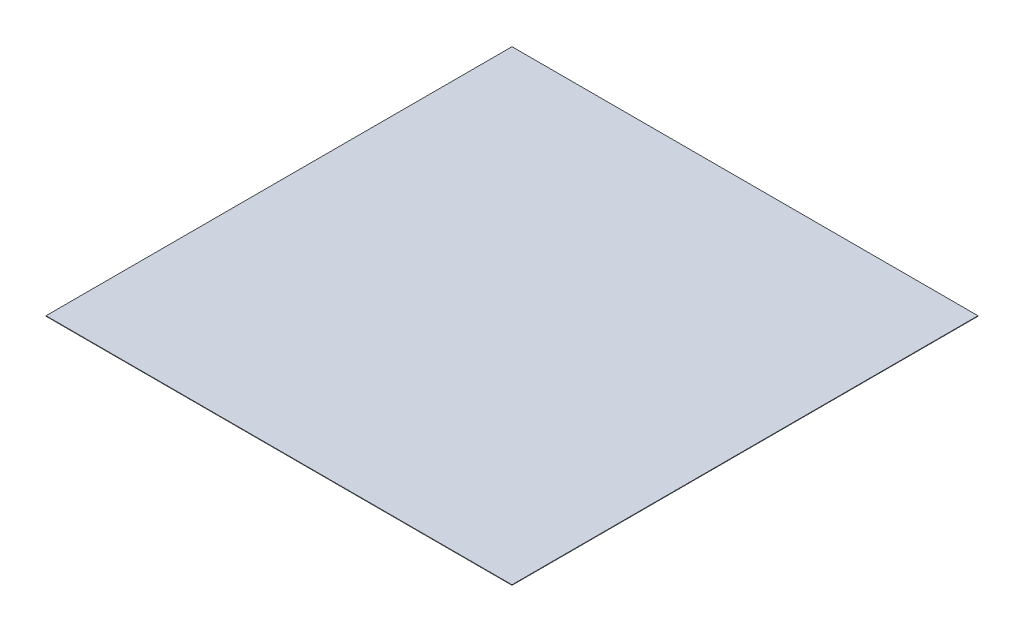
from build123d import *

# Parameters (mm, degrees)
ESBO_O1_W                = 30000
ESBO_O1_H                = 30000
RESSALTO_EXTRUS_O1_DEPTH = 30


with BuildPart() as part:
    # Esboço1 → Ressalto-extrusão1 (new body)
    with BuildSketch(Plane(origin=(0, 0, 0), x_dir=(1, 0, 0), z_dir=(0, 1, 0))):
        Rectangle(ESBO_O1_W, ESBO_O1_H)
    extrude(amount=RESSALTO_EXTRUS_O1_DEPTH)


solid = part.part
